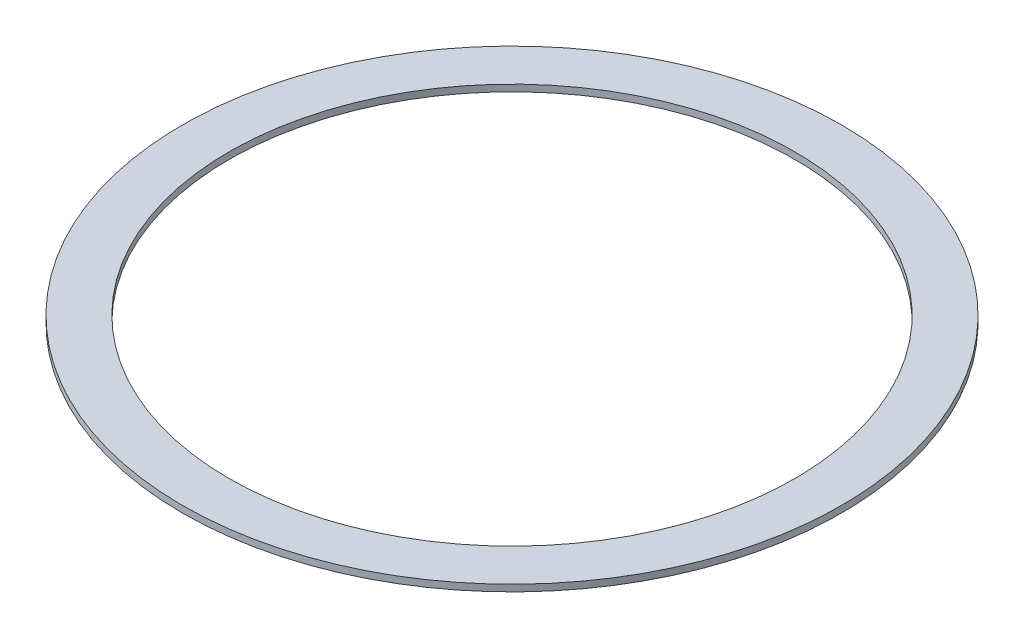
from build123d import *

# Parameters (mm, degrees)
ESBO_O1_R                = 99
ESBO_O1_R_2              = 85
RESSALTO_EXTRUS_O1_DEPTH = 2


with BuildPart() as part:
    # Esboço1 → Ressalto-extrusão1 (new body)
    with BuildSketch(Plane(origin=(0, 0, 0), x_dir=(1, 0, 0), z_dir=(0, 1, 0))):
        Circle(ESBO_O1_R)
        Circle(ESBO_O1_R_2, mode=Mode.SUBTRACT)
    extrude(amount=RESSALTO_EXTRUS_O1_DEPTH)


solid = part.part
